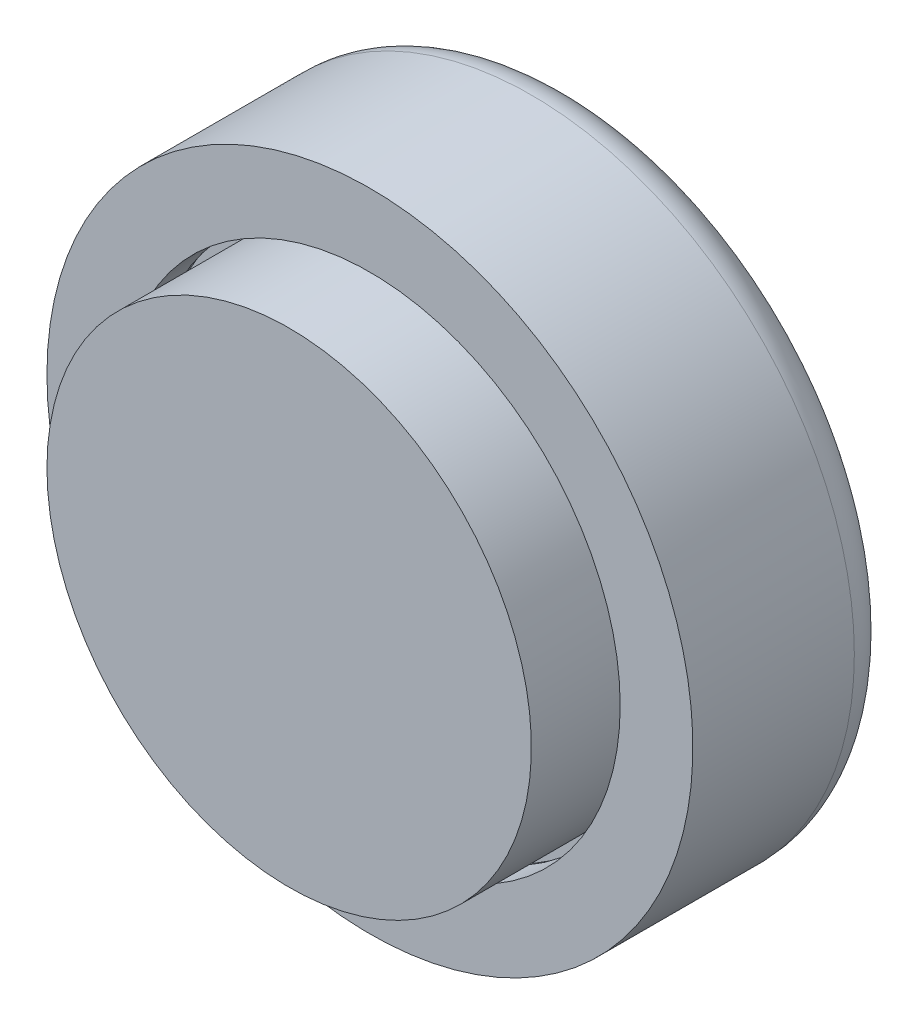
from build123d import *

# Parameters (mm, degrees)
CUT_EXTRUDE2_DEPTH  = 0.4
FILLET1_R           = 1
SKETCH5_W           = 2
SKETCH5_H           = 1.5
BOSS_EXTRUDE1_DEPTH = 2
SKETCH6_W           = 2.4
SKETCH6_H           = 1.9
CUT_EXTRUDE3_DEPTH  = 3


with BuildPart() as part:
    # Sketch3 → Revolve3 (revolve)
    with BuildSketch(Plane(origin=(0, 0, 0), x_dir=(1, 0, 0), z_dir=(0, 1, 0))):
        Polygon((4, 1), (0, 1), (0, 0), (6, 0), (6, 3), (6.25, 3), (6.25, 4), (4, 4), align=None)
    revolve(axis=Axis((0, 0, 0), (0, 0, 1)))

    # Sketch6 → Cut-Extrude3 (cut)
    with BuildSketch(Plane(origin=(0, 0, -4), x_dir=(-1, 0, 0), z_dir=(0, 0, -1))):
        with Locations((0, 3.75)):
            Rectangle(SKETCH6_W, SKETCH6_H)
    extrude(amount=-CUT_EXTRUDE3_DEPTH, mode=Mode.SUBTRACT)


with BuildPart() as body_2:
    # Sketch3_3 → Revolve4 (revolve)
    with BuildSketch(Plane(origin=(0, 0, 0), x_dir=(1, 0, 0), z_dir=(0, 1, 0))):
        Polygon((0, 6), (2, 6), (2, 4), (3.5, 4), (3.5, 6), (6.45, 6), (6.45, 2.8), (6.2, 2.8), (6.2, 2), (8, 2), (8, 7), (0, 7), align=None)
    revolve(axis=Axis((0, 0, 0), (0, 0, 1)))

    # Sketch4 → Cut-Extrude2 (cut)
    with BuildSketch(Plane(origin=(0, 0, -7), x_dir=(-1, 0, 0), z_dir=(0, 0, -1))):
        with BuildLine():
            Line((-4.596153846, 1.75), (-3.80458734, 1.75))
            add(Edge.make_bspline(
                [(-3.80458734, 1.75), (-3.742875626, 1.749568614), (-3.623586185, 1.74873474), (-3.450759386, 1.739338985), (-3.290052454, 1.724888981), (-3.141361797, 1.705010382), (-3.004992253, 1.678705552), (-2.881119669, 1.645711298), (-2.769328297, 1.607624922), (-2.66839237, 1.562808571), (-2.576247577, 1.510557156), (-2.488753155, 1.452353275), (-2.406080898, 1.38606475), (-2.32707063, 1.312970418), (-2.252741997, 1.231733041), (-2.181857161, 1.143698204), (-2.116151703, 1.04758928), (-2.05363949, 0.945710659), (-1.997105511, 0.837630589), (-1.947794463, 0.724269024), (-1.906486299, 0.606355489), (-1.872921276, 0.483764318), (-1.846166079, 0.356902477), (-1.827446007, 0.22551397), (-1.815873072, 0.089720442), (-1.814699095, -0.0023135), (-1.814102564, -0.049078526)],
                knots=[0, 0, 0, 0, 0.000185117, 0.000357834, 0.000519065, 0.000669087, 0.000807689, 0.000935411, 0.00105337, 0.001161647, 0.00126618, 0.001370798, 0.001476572, 0.001583732, 0.001693387, 0.001806607, 0.001922519, 0.002042403, 0.002165021, 0.002288109, 0.00241295, 0.002539502, 0.002669172, 0.002801641, 0.002937422, 0.00307769, 0.00307769, 0.00307769, 0.00307769], degree=3))
            add(Edge.make_bspline(
                [(-1.814102564, -0.049078526), (-1.815664604, -0.115067021), (-1.818739571, -0.244969237), (-1.844641374, -0.435599243), (-1.886533361, -0.618337116), (-1.945437299, -0.791753411), (-2.018462414, -0.954303829), (-2.105699092, -1.103121863), (-2.205868238, -1.237408732), (-2.317802878, -1.356495799), (-2.439000831, -1.458852746), (-2.564949943, -1.546513981), (-2.69687719, -1.615642179), (-2.813123532, -1.659479795), (-2.913923612, -1.686742999), (-3.002424993, -1.702855815), (-3.10295353, -1.717632239), (-3.216446567, -1.729051142), (-3.342406234, -1.739233997), (-3.481334607, -1.744766964), (-3.632781876, -1.749364038), (-3.737976323, -1.749782458), (-3.792668269, -1.75)],
                knots=[0, 0, 0, 0, 0.000197895, 0.000389568, 0.000575968, 0.000759549, 0.000938093, 0.001109685, 0.001275991, 0.00143967, 0.001598838, 0.001751113, 0.001899136, 0.002044464, 0.002122868, 0.002212109, 0.002314138, 0.002427646, 0.002554229, 0.002693195, 0.002844696, 0.003008764, 0.003008764, 0.003008764, 0.003008764], degree=3))
            Line((-3.792668269, -1.75), (-4.596153846, -1.75))
            Line((-4.596153846, -1.75), (-4.596153846, 1.75))
        make_face()
        with BuildLine():
            Line((-3.967948718, 1.121794872), (-3.967948718, -1.121794872))
            Line((-3.967948718, -1.121794872), (-3.639823718, -1.121794872))
            add(Edge.make_bspline(
                [(-3.639823718, -1.121794872), (-3.600781882, -1.121723331), (-3.525691435, -1.121585734), (-3.417277826, -1.11503188), (-3.317022728, -1.108453619), (-3.225202118, -1.095967858), (-3.141147754, -1.082059598), (-3.066014325, -1.062704351), (-2.998253002, -1.042373304), (-2.938691478, -1.016489361), (-2.884137974, -0.98735526), (-2.833627662, -0.953221283), (-2.784871068, -0.91531679), (-2.738779738, -0.872526954), (-2.695179226, -0.825418393), (-2.6543275, -0.773748379), (-2.615679299, -0.717674558), (-2.580226648, -0.656900454), (-2.547829826, -0.592067854), (-2.519090214, -0.523804758), (-2.495260836, -0.45154268), (-2.475455315, -0.375958081), (-2.461302024, -0.29639291), (-2.449592876, -0.213436497), (-2.443556469, -0.126760174), (-2.44272801, -0.067782708), (-2.442307692, -0.037860577)],
                knots=[0, 0, 0, 0, 0.000117096, 0.000225214, 0.000325771, 0.000418388, 0.00050311, 0.000581162, 0.000651011, 0.000715086, 0.00077563, 0.000836301, 0.000897732, 0.000960743, 0.001024745, 0.001090115, 0.001158182, 0.001228888, 0.001301004, 0.001375485, 0.001450868, 0.001529093, 0.001609676, 0.001693165, 0.001780333, 0.001870101, 0.001870101, 0.001870101, 0.001870101], degree=3))
            add(Edge.make_bspline(
                [(-2.442307692, -0.037860577), (-2.443144822, 0.00799226), (-2.444777161, 0.097401739), (-2.46051908, 0.227628596), (-2.486143921, 0.350256692), (-2.522708101, 0.464830919), (-2.568798383, 0.571673292), (-2.626491114, 0.669878629), (-2.693303423, 0.761096645), (-2.746136773, 0.81460806), (-2.772536058, 0.841346154)],
                knots=[0, 0, 0, 0, 0.000137507, 0.000268129, 0.000392852, 0.000512809, 0.00062835, 0.000741145, 0.000853887, 0.000966479, 0.000966479, 0.000966479, 0.000966479], degree=3))
            add(Edge.make_bspline(
                [(-2.772536058, 0.841346154), (-2.798568252, 0.864130624), (-2.851736061, 0.910665325), (-2.945081261, 0.966425797), (-3.047942838, 1.015416837), (-3.162673955, 1.054261268), (-3.288165787, 1.084981101), (-3.425165767, 1.106167818), (-3.572940229, 1.119782177), (-3.675314933, 1.1211096), (-3.728165064, 1.121794872)],
                knots=[0, 0, 0, 0, 0.000103595, 0.000211582, 0.000324802, 0.000444978, 0.000574215, 0.000711958, 0.000860493, 0.001019003, 0.001019003, 0.001019003, 0.001019003], degree=3))
            Line((-3.728165064, 1.121794872), (-3.967948718, 1.121794872))
        make_face(mode=Mode.SUBTRACT)
        with BuildLine():
            Line((-0.673076923, 1.75), (0.058894231, 1.75))
            add(Edge.make_bspline(
                [(0.058894231, 1.75), (0.107277301, 1.749828268), (0.200331575, 1.749497979), (0.334510754, 1.744286889), (0.457772783, 1.73703523), (0.570300162, 1.725969006), (0.67204475, 1.71129653), (0.76310852, 1.694000109), (0.843488808, 1.67428713), (0.913863512, 1.649723202), (0.977373202, 1.622015463), (1.036573064, 1.590178764), (1.092769132, 1.554567615), (1.145585799, 1.514244991), (1.195482052, 1.469936286), (1.242552024, 1.421596899), (1.286130572, 1.368816932), (1.325947858, 1.311929887), (1.362238108, 1.25208602), (1.394311078, 1.189203166), (1.420392871, 1.123237592), (1.44343893, 1.055142645), (1.46003826, 0.983944894), (1.471582852, 0.910337461), (1.48003535, 0.83406124), (1.480521328, 0.782242562), (1.480769231, 0.755809295)],
                knots=[0, 0, 0, 0, 0.000145139, 0.000279143, 0.000402781, 0.00051552, 0.000618244, 0.00071106, 0.000793533, 0.000866261, 0.000934389, 0.001001202, 0.00106772, 0.001133767, 0.001200318, 0.00126775, 0.001335975, 0.001405418, 0.00147588, 0.001545802, 0.001616889, 0.001688503, 0.001761288, 0.001835865, 0.001911978, 0.001991232, 0.001991232, 0.001991232, 0.001991232], degree=3))
            add(Edge.make_bspline(
                [(1.480769231, 0.755809295), (1.480125269, 0.728219036), (1.478862576, 0.674119568), (1.472061028, 0.594651861), (1.459629933, 0.518622717), (1.440801233, 0.446254741), (1.419160087, 0.376647229), (1.390382915, 0.311084482), (1.357905031, 0.248612986), (1.319331998, 0.190116424), (1.276999979, 0.134295469), (1.22776873, 0.083288831), (1.174827682, 0.034355094), (1.115200825, -0.009440697), (1.051516566, -0.051059855), (0.982509565, -0.088777897), (0.908630187, -0.123542965), (0.856689325, -0.142930369), (0.830128205, -0.152844551)],
                knots=[0, 0, 0, 0, 8.278e-05, 0.000162316, 0.000239082, 0.000313563, 0.00038651, 0.000457489, 0.000528056, 0.000597481, 0.00066746, 0.000737887, 0.000809857, 0.000883475, 0.000959513, 0.001037964, 0.001119203, 0.001204224, 0.001204224, 0.001204224, 0.001204224], degree=3))
            Line((0.830128205, -0.152844551), (1.637820513, -1.75))
            Line((1.637820513, -1.75), (0.939503205, -1.75))
            Line((0.939503205, -1.75), (0.168269231, -0.224358974))
            Line((0.168269231, -0.224358974), (-0.044871795, -0.224358974))
            Line((-0.044871795, -0.224358974), (-0.044871795, -1.75))
            Line((-0.044871795, -1.75), (-0.673076923, -1.75))
            Line((-0.673076923, -1.75), (-0.673076923, 1.75))
        make_face()
        with BuildLine():
            Line((-0.044871795, 0.403846154), (0.199819712, 0.403846154))
            add(Edge.make_bspline(
                [(0.199819712, 0.403846154), (0.229735282, 0.404183083), (0.287017172, 0.40482823), (0.369396053, 0.40782069), (0.444215723, 0.41503104), (0.511797484, 0.424141047), (0.572481399, 0.434659866), (0.625726192, 0.449733972), (0.672352281, 0.465886258), (0.711807147, 0.48595936), (0.745516478, 0.508786831), (0.774622328, 0.534719405), (0.798697039, 0.564733058), (0.818511754, 0.598012147), (0.833925448, 0.634851019), (0.845176263, 0.674845265), (0.851463806, 0.718450472), (0.852187209, 0.748544002), (0.852564103, 0.764222756)],
                knots=[0, 0, 0, 0, 8.9755e-05, 0.000171861, 0.000247208, 0.00031513, 0.000376461, 0.000431743, 0.000480981, 0.000524253, 0.000564118, 0.000602839, 0.000640725, 0.000679082, 0.000718669, 0.000760178, 0.000803409, 0.000850432, 0.000850432, 0.000850432, 0.000850432], degree=3))
            add(Edge.make_bspline(
                [(0.852564103, 0.764222756), (0.851851551, 0.782771868), (0.850451874, 0.819208159), (0.836562737, 0.871663643), (0.81445423, 0.920214782), (0.784149523, 0.96464221), (0.745984684, 1.00359036), (0.70218752, 1.037923465), (0.651812783, 1.065071516), (0.605169567, 1.082978081), (0.562735143, 1.093691763), (0.524439414, 1.101675505), (0.48009273, 1.107333812), (0.42966161, 1.113335453), (0.373274606, 1.117227214), (0.310624375, 1.120067423), (0.241890847, 1.121229493), (0.19397705, 1.121600986), (0.168970353, 1.121794872)],
                knots=[0, 0, 0, 0, 5.5548e-05, 0.000109114, 0.000161511, 0.00021499, 0.000269533, 0.000324507, 0.000381303, 0.00044055, 0.000473881, 0.00051252, 0.000557833, 0.000607927, 0.000664874, 0.000727337, 0.000796061, 0.000871084, 0.000871084, 0.000871084, 0.000871084], degree=3))
            Line((0.168970353, 1.121794872), (-0.044871795, 1.121794872))
            Line((-0.044871795, 1.121794872), (-0.044871795, 0.403846154))
        make_face(mode=Mode.SUBTRACT)
        with BuildLine():
            Line((4.461538462, 1.282351763), (3.991786859, 0.852564103))
            add(Edge.make_bspline(
                [(3.991786859, 0.852564103), (3.971664715, 0.880948479), (3.933033003, 0.935442524), (3.870415029, 1.008411334), (3.808079807, 1.07065916), (3.745449839, 1.121925958), (3.681969998, 1.161900244), (3.617750474, 1.190202481), (3.553155346, 1.208194481), (3.509757392, 1.210434918), (3.48838141, 1.211538462)],
                knots=[0, 0, 0, 0, 0.000104333, 0.000200305, 0.000288057, 0.000368319, 0.000442638, 0.000512332, 0.000578316, 0.000642364, 0.000642364, 0.000642364, 0.000642364], degree=3))
            add(Edge.make_bspline(
                [(3.48838141, 1.211538462), (3.468442508, 1.210839206), (3.429945725, 1.209489126), (3.375065706, 1.196069437), (3.326342444, 1.172909025), (3.283823489, 1.142624837), (3.250142204, 1.106139412), (3.22325031, 1.067875583), (3.208107914, 1.025640968), (3.206114877, 0.996632532), (3.205128205, 0.982271635)],
                knots=[0, 0, 0, 0, 5.9744e-05, 0.000115349, 0.000168041, 0.000220774, 0.000270869, 0.000316372, 0.00036028, 0.000403329, 0.000403329, 0.000403329, 0.000403329], degree=3))
            add(Edge.make_bspline(
                [(3.205128205, 0.982271635), (3.205746502, 0.967703647), (3.206991667, 0.938365745), (3.219018261, 0.895367395), (3.237145772, 0.853353002), (3.254467348, 0.827776842), (3.263321314, 0.814703526)],
                knots=[0, 0, 0, 0, 4.3611e-05, 8.7826e-05, 0.000133031, 0.000180298, 0.000180298, 0.000180298, 0.000180298], degree=3))
            add(Edge.make_bspline(
                [(3.263321314, 0.814703526), (3.271370527, 0.804541774), (3.289898751, 0.781150764), (3.32522828, 0.74410305), (3.369594749, 0.698716357), (3.424705473, 0.646551401), (3.488272653, 0.585732126), (3.563242712, 0.518649361), (3.647457683, 0.443225631), (3.707315734, 0.390703276), (3.738681891, 0.36318109)],
                knots=[0, 0, 0, 0, 3.8873e-05, 8.948e-05, 0.000153436, 0.000229303, 0.000317089, 0.000417357, 0.00053107, 0.000656255, 0.000656255, 0.000656255, 0.000656255], degree=3))
            add(Edge.make_bspline(
                [(3.738681891, 0.36318109), (3.768123541, 0.337700826), (3.823997677, 0.28934458), (3.903495477, 0.220710653), (3.973360803, 0.158962381), (4.034611433, 0.105026476), (4.086318868, 0.058337026), (4.128700485, 0.018670855), (4.162273905, -0.013199809), (4.181358429, -0.032449709), (4.189503205, -0.040665064)],
                knots=[0, 0, 0, 0, 0.00011681, 0.000221681, 0.000315075, 0.000396532, 0.000466521, 0.000524065, 0.000570677, 0.000605381, 0.000605381, 0.000605381, 0.000605381], degree=3))
            add(Edge.make_bspline(
                [(4.189503205, -0.040665064), (4.22040279, -0.074105032), (4.279802642, -0.138388395), (4.357001511, -0.238007389), (4.420538677, -0.335255841), (4.469692234, -0.431963637), (4.506814977, -0.529526078), (4.532987003, -0.630335878), (4.548661603, -0.735446436), (4.550401849, -0.807171561), (4.551282051, -0.843449519)],
                knots=[0, 0, 0, 0, 0.000136539, 0.000262476, 0.000377607, 0.00048453, 0.00058727, 0.000690153, 0.000796447, 0.000905231, 0.000905231, 0.000905231, 0.000905231], degree=3))
            add(Edge.make_bspline(
                [(4.551282051, -0.843449519), (4.550655546, -0.878797941), (4.54942632, -0.948152859), (4.534370652, -1.049643451), (4.512902153, -1.146774353), (4.479708089, -1.238488642), (4.439251359, -1.326291782), (4.388533006, -1.408816077), (4.328971254, -1.486896708), (4.260704341, -1.559137888), (4.185193029, -1.624691752), (4.10419997, -1.68304935), (4.016933174, -1.73123098), (3.924138235, -1.770905116), (3.825864822, -1.801462666), (3.72223001, -1.824047543), (3.613075283, -1.837602631), (3.538433707, -1.839019654), (3.500300481, -1.83974359)],
                knots=[0, 0, 0, 0, 0.000105953, 0.000207884, 0.000307206, 0.000403889, 0.000499869, 0.000596786, 0.000693825, 0.000794014, 0.0008944, 0.000993427, 0.001092919, 0.001192806, 0.001295697, 0.001401176, 0.001510663, 0.001625023, 0.001625023, 0.001625023, 0.001625023], degree=3))
            add(Edge.make_bspline(
                [(3.500300481, -1.83974359), (3.470366223, -1.839212536), (3.411079225, -1.838160745), (3.323699154, -1.829573749), (3.239323817, -1.815715249), (3.158048256, -1.79585188), (3.079506311, -1.770682298), (3.003694755, -1.739938617), (2.931136941, -1.703144322), (2.861283862, -1.66105605), (2.79447509, -1.612186023), (2.729865855, -1.557533371), (2.668097917, -1.496257513), (2.608874617, -1.428503364), (2.552574883, -1.35407906), (2.497355821, -1.274021098), (2.445671533, -1.18684371), (2.413743849, -1.125688067), (2.397435897, -1.094451122)],
                knots=[0, 0, 0, 0, 8.9787e-05, 0.000177831, 0.000263126, 0.00034611, 0.000428593, 0.000510357, 0.000591254, 0.000672417, 0.000754739, 0.000839305, 0.000926065, 0.001015502, 0.001109035, 0.001205881, 0.001307125, 0.001412829, 0.001412829, 0.001412829, 0.001412829], degree=3))
            Line((2.397435897, -1.094451122), (2.949919872, -0.762820513))
            add(Edge.make_bspline(
                [(2.949919872, -0.762820513), (2.970318682, -0.798278527), (3.009424946, -0.86625457), (3.075694165, -0.957588999), (3.143583597, -1.035801818), (3.214662785, -1.099510612), (3.288067431, -1.149567249), (3.364152099, -1.185341194), (3.442970243, -1.207485226), (3.496657582, -1.210189524), (3.5234375, -1.211538462)],
                knots=[0, 0, 0, 0, 0.000122646, 0.000235123, 0.000337949, 0.000432798, 0.000520693, 0.0006035, 0.000684117, 0.000764351, 0.000764351, 0.000764351, 0.000764351], degree=3))
            add(Edge.make_bspline(
                [(3.5234375, -1.211538462), (3.550676511, -1.210436846), (3.603524159, -1.208299551), (3.678957415, -1.188558004), (3.748117479, -1.157562327), (3.807898929, -1.11333577), (3.858518091, -1.062291601), (3.895877938, -1.005502629), (3.919347646, -0.944058332), (3.921828963, -0.901375082), (3.923076923, -0.879907853)],
                knots=[0, 0, 0, 0, 8.1575e-05, 0.000158267, 0.000232307, 0.000307618, 0.000380007, 0.000446905, 0.00051034, 0.000574526, 0.000574526, 0.000574526, 0.000574526], degree=3))
            add(Edge.make_bspline(
                [(3.923076923, -0.879907853), (3.921924483, -0.859936089), (3.919583411, -0.819365364), (3.902339795, -0.75904322), (3.875382764, -0.698748508), (3.843490695, -0.649293155), (3.811036522, -0.607885528), (3.780003012, -0.572007693), (3.742212406, -0.532368966), (3.697760525, -0.488919484), (3.647234694, -0.441276752), (3.590592351, -0.389445434), (3.527184882, -0.333882102), (3.482368358, -0.29603291), (3.458934295, -0.276241987)],
                knots=[0, 0, 0, 0, 5.9859e-05, 0.000121597, 0.000186877, 0.000257482, 0.000297452, 0.000344677, 0.000399728, 0.000461701, 0.000531137, 0.000608059, 0.000692021, 0.000784039, 0.000784039, 0.000784039, 0.000784039], degree=3))
            add(Edge.make_bspline(
                [(3.458934295, -0.276241987), (3.414385208, -0.238549188), (3.328882028, -0.166205298), (3.208055185, -0.05935565), (3.099179382, 0.040505137), (3.003194985, 0.13461156), (2.918879006, 0.221225691), (2.846802468, 0.301051045), (2.787757166, 0.374703364), (2.725624717, 0.461939606), (2.666586469, 0.568242962), (2.615560668, 0.696138223), (2.582457282, 0.824017255), (2.578748508, 0.909868194), (2.576923077, 0.952123397)],
                knots=[0, 0, 0, 0, 0.000175062, 0.000335996, 0.000483855, 0.000618216, 0.0007392, 0.000846451, 0.000940727, 0.001022233, 0.001167556, 0.001304131, 0.00143473, 0.001561313, 0.001561313, 0.001561313, 0.001561313], degree=3))
            add(Edge.make_bspline(
                [(2.576923077, 0.952123397), (2.577682271, 0.98208852), (2.579177966, 1.04112303), (2.592519793, 1.127924675), (2.612459663, 1.211680969), (2.641418077, 1.292086331), (2.679002603, 1.369040051), (2.72464755, 1.442918848), (2.779061697, 1.513042759), (2.840382767, 1.579365297), (2.907942886, 1.639976549), (2.980139459, 1.693472052), (3.056563847, 1.738655132), (3.136748524, 1.776137778), (3.221190361, 1.804828362), (3.30926728, 1.825165678), (3.40110561, 1.837261665), (3.463572059, 1.838905974), (3.495392628, 1.83974359)],
                knots=[0, 0, 0, 0, 8.9842e-05, 0.000176999, 0.000262874, 0.000347814, 0.000432791, 0.000519374, 0.000607862, 0.000698654, 0.00079001, 0.000879756, 0.000967774, 0.001055918, 0.001144828, 0.001234796, 0.001326718, 0.001422163, 0.001422163, 0.001422163, 0.001422163], degree=3))
            add(Edge.make_bspline(
                [(3.495392628, 1.83974359), (3.536630511, 1.83823502), (3.618780759, 1.835229789), (3.740242269, 1.811729864), (3.858880795, 1.774773756), (3.954481942, 1.730190278), (4.03054999, 1.687002242), (4.088849044, 1.647240139), (4.148171469, 1.601690512), (4.208995663, 1.550209824), (4.270191421, 1.49182811), (4.333498828, 1.427935192), (4.398055245, 1.357978887), (4.44000668, 1.308002427), (4.461538462, 1.282351763)],
                knots=[0, 0, 0, 0, 0.000123638, 0.0002463, 0.000369811, 0.000495611, 0.000561878, 0.000632077, 0.000707101, 0.000786191, 0.000871003, 0.000960739, 0.001056009, 0.001156468, 0.001156468, 0.001156468, 0.001156468], degree=3))
        make_face()
    extrude(amount=-CUT_EXTRUDE2_DEPTH, mode=Mode.SUBTRACT)

    # Fillet1
    fillet1_edges = [body_2.edges().sort_by_distance(p)[0] for p in [
        (-8, 0, -7),
    ]]
    fillet(fillet1_edges, radius=FILLET1_R)

    # Sketch5 → Boss-Extrude1 (add)
    with BuildSketch(Plane.XY.offset(-6)):
        with Locations((0, 3.75)):
            Rectangle(SKETCH5_W, SKETCH5_H)
    extrude(amount=BOSS_EXTRUDE1_DEPTH)


solid = Compound([part.part, body_2.part])
